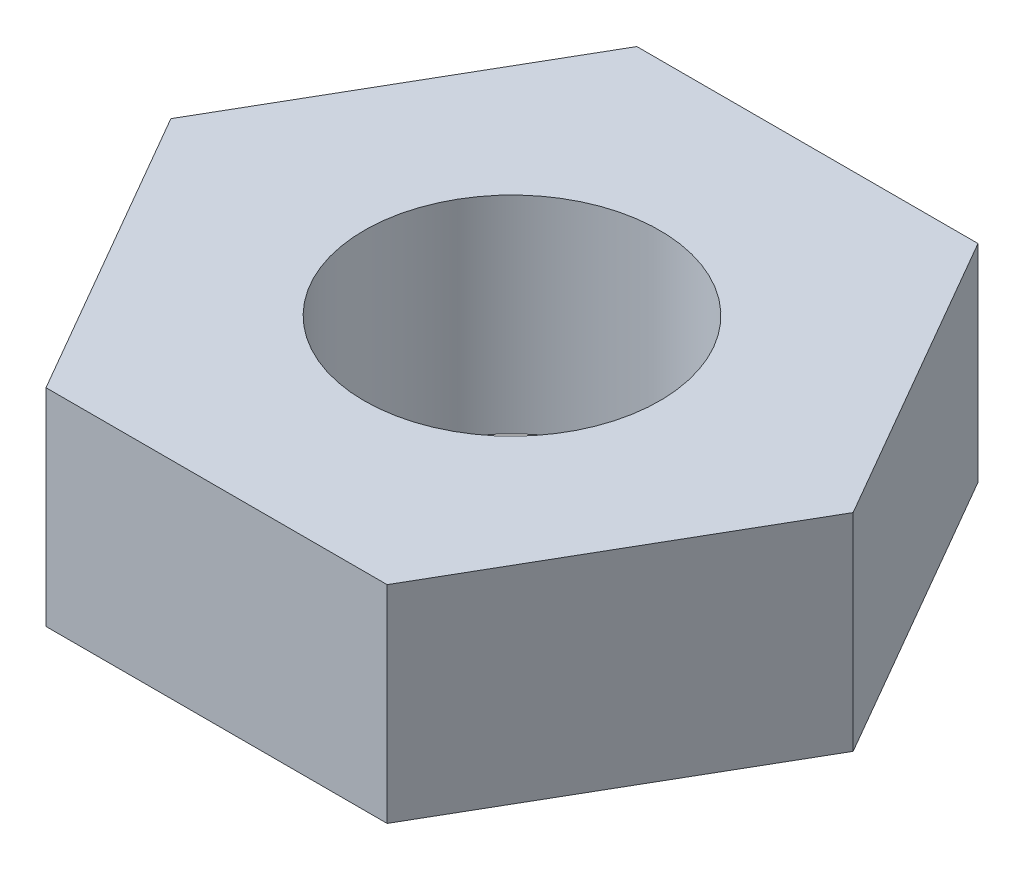
from build123d import *

# Parameters (mm, degrees)
SKETCH1_R           = 2.5
BOSS_EXTRUDE1_DEPTH = 3.5


with BuildPart() as part:
    # Sketch1 → Boss-Extrude1 (new body)
    with BuildSketch(Plane(origin=(0, 0, 0), x_dir=(1, 0, 0), z_dir=(0, 1, 0))):
        Polygon((5.773502692, 0), (2.886751346, 5), (-2.886751346, 5), (-5.773502692, 0), (-2.886751346, -5), (2.886751346, -5), align=None)
        Circle(SKETCH1_R, mode=Mode.SUBTRACT)
    extrude(amount=BOSS_EXTRUDE1_DEPTH)


solid = part.part
